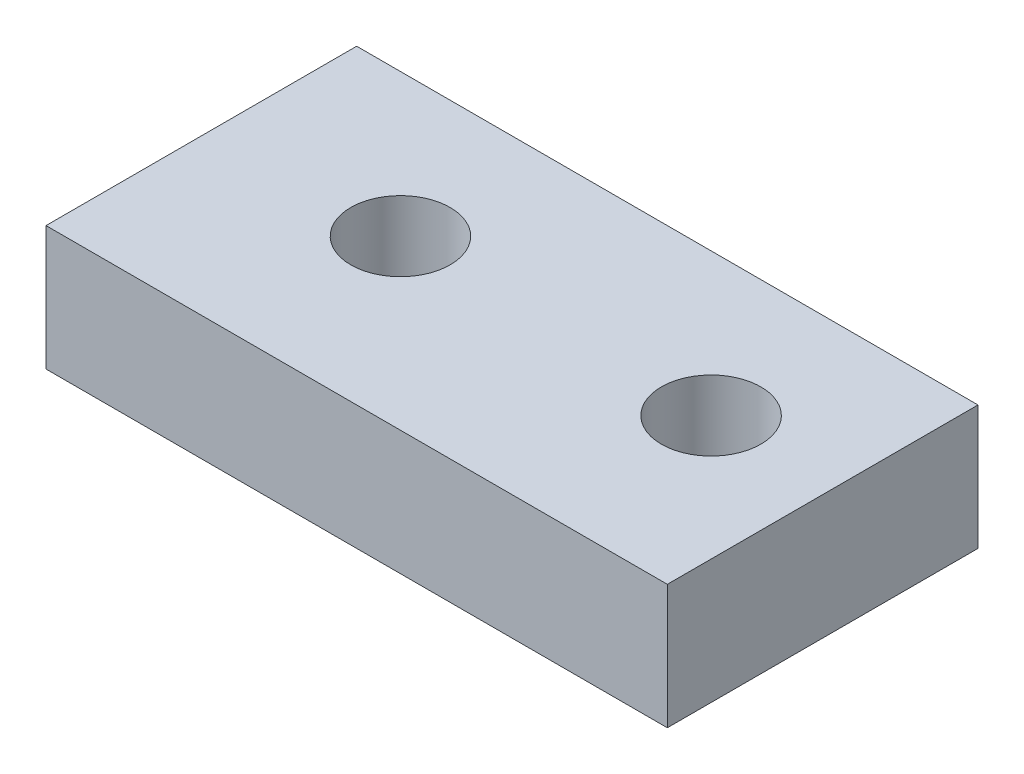
from build123d import *

# Parameters (mm, degrees)
SKETCH1_W           = 10
SKETCH1_H           = 5
SKETCH1_R           = 0.8
BOSS_EXTRUDE1_DEPTH = 2


with BuildPart() as part:
    # Sketch1 → Boss-Extrude1 (new body)
    with BuildSketch(Plane(origin=(0, 0, 0), x_dir=(1, 0, 0), z_dir=(0, 1, 0))):
        with Locations((1.230435368, -0.204567399)):
            Rectangle(SKETCH1_W, SKETCH1_H)
        with Locations((-0.769564632, 0)):
            Circle(SKETCH1_R, mode=Mode.SUBTRACT)
        with Locations((4.230435368, 0)):
            Circle(SKETCH1_R, mode=Mode.SUBTRACT)
    extrude(amount=BOSS_EXTRUDE1_DEPTH)


solid = part.part
